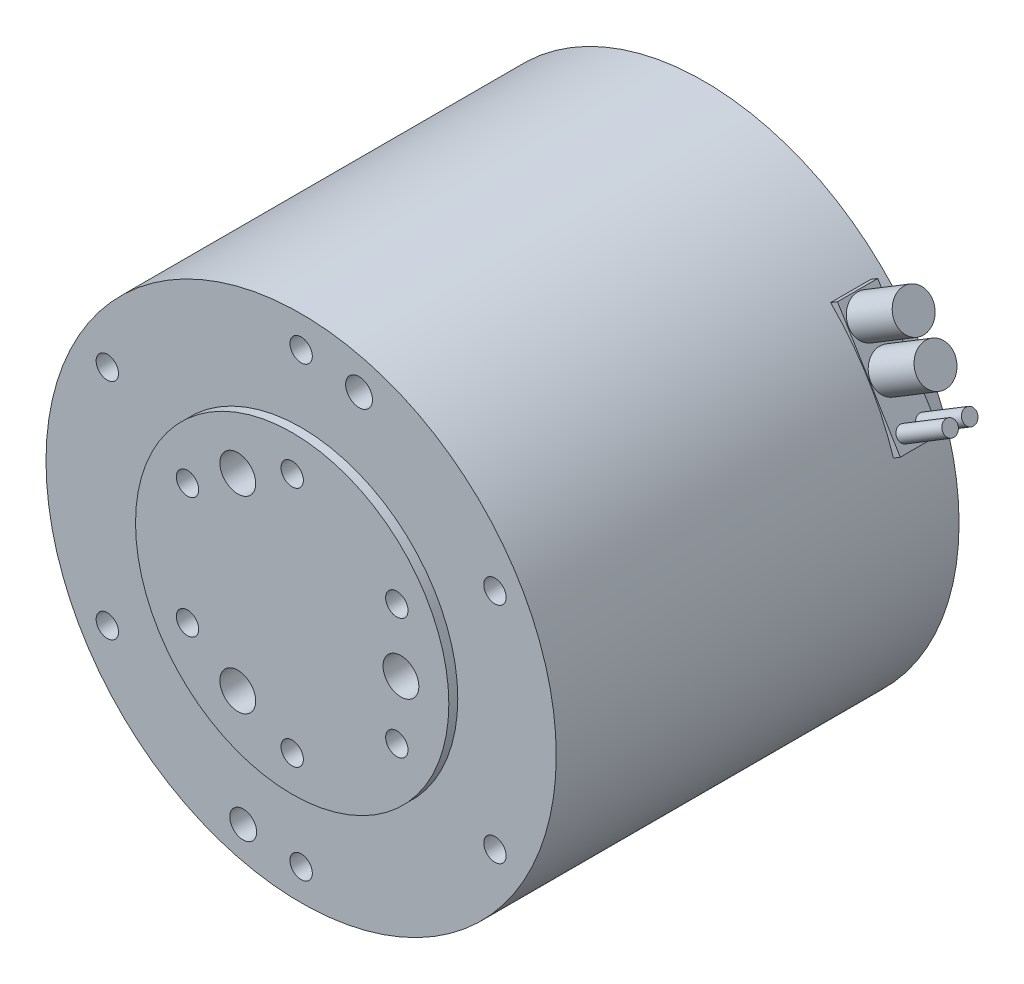
from build123d import *

# Parameters (mm, degrees)
SKETCH_1_R             = 28.5
EXTRUDE_1_DEPTH        = 45
SKETCH_2_R             = 17.5
EXTRUDE_2_DEPTH        = 1
SKETCH_3_R             = 1
SKETCH_3_R_2           = 1.5
CUT_EXTRUDE_1_DEPTH    = 5
HOLE_WIZARD_M3_1_D     = 2.5
HOLE_WIZARD_M3_1_DEPTH = 5
HOLE_WIZARD_M3_1_TIP   = 0.751075774
SKETCH_7_R             = 1
SKETCH_7_R_2           = 2
CUT_EXTRUDE_2_DEPTH    = 5
HOLE_WIZARD_M3_2_D     = 2.5
HOLE_WIZARD_M3_2_DEPTH = 7
HOLE_WIZARD_M3_2_TIP   = 0.751075774
SKETCH_10_R            = 1
CUT_EXTRUDE_3_DEPTH    = 4
HOLE_WIZARD_M3_3_D     = 2.5
HOLE_WIZARD_M3_3_DEPTH = 4
HOLE_WIZARD_M3_3_TIP   = 0.751075774
SKETCH_12_W            = 4.5
SKETCH_12_H            = 13.5
EXTRUDE_3_DEPTH        = 16.4
SKETCH_14_R            = 2.127458751
SKETCH_14_R_2          = 0.821166135
EXTRUDE_4_DEPTH        = 6


with BuildPart() as part:
    # 草图1 → 凸台-拉伸1 (new body)
    with BuildSketch(Plane.XY):
        Circle(SKETCH_1_R)
    extrude(amount=EXTRUDE_1_DEPTH)

    # 草图2 → 凸台-拉伸2 (add)
    with BuildSketch(Plane.XY.offset(45)):
        Circle(SKETCH_2_R)
    extrude(amount=EXTRUDE_2_DEPTH)

    # 草图3 → 切除-拉伸1 (cut)
    with BuildSketch(Plane.XY.offset(45)):
        with Locations((0, 25)):
            Circle(SKETCH_3_R)
        with Locations((21.650635095, 12.5)):
            Circle(SKETCH_3_R)
        with Locations((21.650635095, -12.5)):
            Circle(SKETCH_3_R)
        with Locations((0, -25)):
            Circle(SKETCH_3_R)
        with Locations((-21.650635095, -12.5)):
            Circle(SKETCH_3_R)
        with Locations((-21.650635095, 12.5)):
            Circle(SKETCH_3_R)
        with Locations((-6.470476128, -24.148145657)):
            Circle(SKETCH_3_R_2)
        with Locations((6.470476128, 24.148145657)):
            Circle(SKETCH_3_R_2)
    extrude(amount=-CUT_EXTRUDE_1_DEPTH, mode=Mode.SUBTRACT)

    # M3 螺纹孔1
    with Locations(Plane.XY.offset(45)):
        with Locations((-21.650635095, 12.5), (0, 25), (21.650635095, 12.5), (21.650635095, -12.5), (0, -25), (-21.650635095, -12.5)):
            Hole(HOLE_WIZARD_M3_1_D / 2, depth=HOLE_WIZARD_M3_1_DEPTH)
            with Locations((0, 0, -(HOLE_WIZARD_M3_1_DEPTH + HOLE_WIZARD_M3_1_TIP / 2))):  # 118° drill point
                Cone(0, HOLE_WIZARD_M3_1_D / 2, HOLE_WIZARD_M3_1_TIP, mode=Mode.SUBTRACT)

    # 草图7 → 切除-拉伸2 (cut)
    with BuildSketch(Plane.XY.offset(46)):
        with Locations((0, 13.5)):
            Circle(SKETCH_7_R)
        with Locations((11.691342951, 6.75)):
            Circle(SKETCH_7_R)
        with Locations((11.691342951, -6.75)):
            Circle(SKETCH_7_R)
        with Locations((0, -13.5)):
            Circle(SKETCH_7_R)
        with Locations((-11.691342951, -6.75)):
            Circle(SKETCH_7_R)
        with Locations((-11.691342951, 6.75)):
            Circle(SKETCH_7_R)
        with Locations((12.15, 0)):
            Circle(SKETCH_7_R_2)
        with Locations((-6.075, -10.522208656)):
            Circle(SKETCH_7_R_2)
        with Locations((-6.075, 10.522208656)):
            Circle(SKETCH_7_R_2)
    extrude(amount=-CUT_EXTRUDE_2_DEPTH, mode=Mode.SUBTRACT)

    # M3 螺纹孔2
    with Locations(Plane.XY.offset(46)):
        with Locations((-11.691342951, 6.75), (0, 13.5), (11.691342951, 6.75), (11.691342951, -6.75), (0, -13.5), (-11.691342951, -6.75)):
            Hole(HOLE_WIZARD_M3_2_D / 2, depth=HOLE_WIZARD_M3_2_DEPTH)
            with Locations((0, 0, -(HOLE_WIZARD_M3_2_DEPTH + HOLE_WIZARD_M3_2_TIP / 2))):  # 118° drill point
                Cone(0, HOLE_WIZARD_M3_2_D / 2, HOLE_WIZARD_M3_2_TIP, mode=Mode.SUBTRACT)

    # 草图10 → 切除-拉伸3 (cut)
    with BuildSketch(Plane(origin=(0, 0, 0), x_dir=(-1, 0, 0), z_dir=(0, 0, -1))):
        with Locations((-4.5, 18.459414942)):
            Circle(SKETCH_10_R)
        with Locations((18.459414942, 4.5)):
            Circle(SKETCH_10_R)
        with Locations((4.5, -18.459414942)):
            Circle(SKETCH_10_R)
        with Locations((-18.459414942, -4.5)):
            Circle(SKETCH_10_R)
    extrude(amount=-CUT_EXTRUDE_3_DEPTH, mode=Mode.SUBTRACT)

    # M3 螺纹孔3
    with Locations(Plane(origin=(4.5, 18.459414942, 0), x_dir=(-1, 0, 0), z_dir=(0, 0, -1))):
        with Locations((0, 0), (-13.959414942, -22.959414942), (9, -36.918829884), (22.959414942, -13.959414942)):
            Hole(HOLE_WIZARD_M3_3_D / 2, depth=HOLE_WIZARD_M3_3_DEPTH)
            with Locations((0, 0, -(HOLE_WIZARD_M3_3_DEPTH + HOLE_WIZARD_M3_3_TIP / 2))):  # 118° drill point
                Cone(0, HOLE_WIZARD_M3_3_D / 2, HOLE_WIZARD_M3_3_TIP, mode=Mode.SUBTRACT)

    # 草图12 → 凸台-拉伸3 (add)
    with BuildSketch(Plane(origin=(10.411631287, 6.330312934, 0), x_dir=(0, 0, -1), z_dir=(0.854460947, 0.51951563, 0))):
        with Locations((-3.75, 0)):
            Rectangle(SKETCH_12_W, SKETCH_12_H)
    extrude(amount=EXTRUDE_3_DEPTH)

    # 草图14 → 凸台-拉伸4 (add)
    with BuildSketch(Plane(origin=(24.424790822, 14.850369263, 0), x_dir=(0, 0, -1), z_dir=(0.854460947, 0.51951563, 0))):
        with Locations((-3.791208739, 4.492201758)):
            Circle(SKETCH_14_R)
        with Locations((-3.791208739, -0.213214329)):
            Circle(SKETCH_14_R)
        with Locations((-4.780701919, -5.253978847)):
            Circle(SKETCH_14_R_2)
        with Locations((-2.591443579, -5.253978847)):
            Circle(SKETCH_14_R_2)
    extrude(amount=EXTRUDE_4_DEPTH)


solid = part.part
